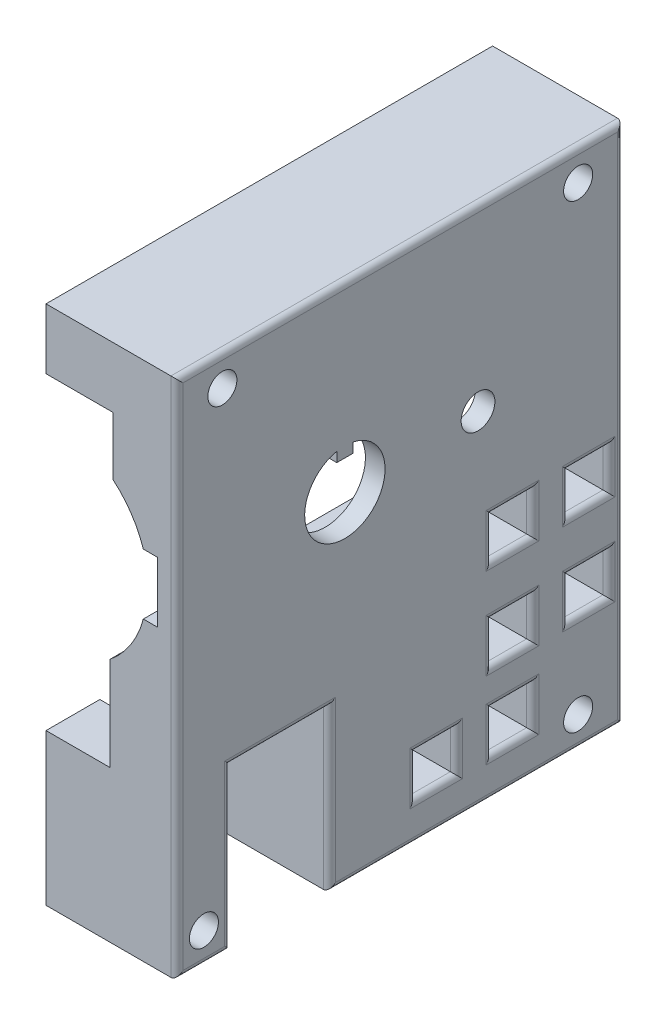
from build123d import *

# Parameters (mm, degrees)
PROFILEEXTRUDE_DEPTH = 73.76
HOSEWINDOW_W         = 16.29
HOSEWINDOW_H         = 26.5
HOSEWINDOWCUT_DEPTH  = 22.63
CAGESCREWS_R         = 2.4
CAGESCREWSCUT_DEPTH  = 22.63
AXLEHOLECUT_DEPTH    = 22.63
SETSCREWS_R          = 2.426338021
SETSCREWS_R_2        = 2.788762315
SETSCREWSCUT_DEPTH   = 22.63
SKETCH1_W            = 6.7
SKETCH1_H            = 6.7
CUT_EXTRUDE1_DEPTH   = 22.63
FILLET1_R            = 1


with BuildPart() as part:
    # Profile → ProfileExtrude (new body)
    with BuildSketch(Plane.XY):
        with BuildLine():
            Line((-6.44073477, -58.62791746), (-6.44073477, -33.62791746))
            Line((-6.44073477, -33.62791746), (4.13926523, -33.62791746))
            Line((4.13926523, -33.62791746), (4.13926523, -18.13791746))
            ThreePointArc((4.13926523, -18.13791746), (7.563334043, -14.326029686), (9.63126523, -9.63791746))
            Line((9.63126523, -9.63791746), (11.94926523, -9.63791746))
            Line((11.94926523, -9.63791746), (11.94926523, 0.36208254))
            Line((11.94926523, 0.36208254), (9.62926523, 0.36208254))
            ThreePointArc((9.62926523, 0.36208254), (7.643946533, 4.440626184), (4.60926523, 7.81208254))
            Line((4.60926523, 7.81208254), (4.60926523, 17.41208254))
            Line((4.60926523, 17.41208254), (-6.44073477, 17.41208254))
            Line((-6.44073477, 17.41208254), (-6.44073477, 27.41208254))
            Line((-6.44073477, 27.41208254), (15.18926523, 27.41208254))
            Line((15.18926523, 27.41208254), (15.18926523, -58.62791746))
            Line((15.18926523, -58.62791746), (-6.44073477, -58.62791746))
        make_face()
    extrude(amount=PROFILEEXTRUDE_DEPTH)

    # HoseWindow → HoseWindowCut (cut, through all)
    with BuildSketch(Plane(origin=(15.18926523, 0, 0), x_dir=(0, 0, -1), z_dir=(1, 0, 0))):
        with Locations((-56.725, -45.37791746)):
            Rectangle(HOSEWINDOW_W, HOSEWINDOW_H)
    extrude(amount=-HOSEWINDOWCUT_DEPTH, mode=Mode.SUBTRACT)

    # CageScrews → CageScrewsCut (cut, through all)
    with BuildSketch(Plane(origin=(15.18926523, 0, 0), x_dir=(0, 0, -1), z_dir=(1, 0, 0))):
        with Locations((-66.26, 22.41208254)):
            Circle(CAGESCREWS_R)
        with Locations((-7.5, 22.41208254)):
            Circle(CAGESCREWS_R)
        with Locations((-7.5, -53.62791746)):
            Circle(CAGESCREWS_R)
        with Locations((-69.31, -53.62791746)):
            Circle(CAGESCREWS_R)
    extrude(amount=-CAGESCREWSCUT_DEPTH, mode=Mode.SUBTRACT)

    # AxleHole → AxleHoleCut (cut, through all)
    with BuildSketch(Plane(origin=(15.18926523, 0, 0), x_dir=(0, 0, -1), z_dir=(1, 0, 0))):
        with BuildLine():
            Line((-44.699, 2.307293484), (-47.361, 2.307293484))
            Line((-47.361, 2.307293484), (-47.361, 3.926293484))
            ThreePointArc((-47.361, 3.926293484), (-46.03, -9.21691746), (-44.699, 3.926293484))
            Line((-44.699, 3.926293484), (-44.699, 2.307293484))
        make_face()
    extrude(amount=-AXLEHOLECUT_DEPTH, mode=Mode.SUBTRACT)

    # SetScrews → SetScrewsCut (cut, through all)
    with BuildSketch(Plane(origin=(15.18926523, 0, 0), x_dir=(0, 0, -1), z_dir=(1, 0, 0))):
        with Locations((-85.624962528, 3.100017238)):
            Circle(SETSCREWS_R)
        with Locations((-24.037149362, -2.017095907)):
            Circle(SETSCREWS_R_2)
    extrude(amount=-SETSCREWSCUT_DEPTH, mode=Mode.SUBTRACT)

    # Sketch1 → Cut-Extrude1 (cut, through all)
    with BuildSketch(Plane(origin=(15.18926523, 0, 0), x_dir=(0, 0, -1), z_dir=(1, 0, 0))):
        with Locations((-18.35, -48.92791746)):
            Rectangle(SKETCH1_W, SKETCH1_H)
        with Locations((-30.95, -48.92791746)):
            Rectangle(SKETCH1_W, SKETCH1_H)
        with Locations((-5.75, -36.22791746)):
            Rectangle(SKETCH1_W, SKETCH1_H)
        with Locations((-18.35, -36.22791746)):
            Rectangle(SKETCH1_W, SKETCH1_H)
        with Locations((-5.75, -21.22791746)):
            Rectangle(SKETCH1_W, SKETCH1_H)
        with Locations((-18.35, -21.22791746)):
            Rectangle(SKETCH1_W, SKETCH1_H)
    extrude(amount=-CUT_EXTRUDE1_DEPTH, mode=Mode.SUBTRACT)

    # Fillet1
    fillet1_edges = [part.edges().sort_by_distance(p)[0] for p in [
        (15.18926523, -45.57791746, 18.35),
        (15.18926523, -48.92791746, 21.7),
        (15.18926523, -52.27791746, 18.35),
        (15.18926523, -48.92791746, 15),
        (15.18926523, -48.92791746, 34.3),
        (15.18926523, -52.27791746, 30.95),
        (15.18926523, -48.92791746, 27.6),
        (15.18926523, -45.57791746, 30.95),
        (15.18926523, -36.22791746, 9.1),
        (15.18926523, -39.57791746, 5.75),
        (15.18926523, -36.22791746, 2.4),
        (15.18926523, -32.87791746, 5.75),
        (15.18926523, -36.22791746, 21.7),
        (15.18926523, -39.57791746, 18.35),
        (15.18926523, -36.22791746, 15),
        (15.18926523, -32.87791746, 18.35),
        (15.18926523, -15.60791746, 0),
        (15.18926523, -21.22791746, 9.1),
        (15.18926523, -24.57791746, 5.75),
        (15.18926523, -21.22791746, 2.4),
        (15.18926523, -17.87791746, 5.75),
        (15.18926523, -21.22791746, 21.7),
        (15.18926523, -24.57791746, 18.35),
        (15.18926523, -21.22791746, 15),
        (15.18926523, -17.87791746, 18.35),
        (15.18926523, -58.62791746, 69.315),
        (15.18926523, 27.41208254, 36.88),
        (15.18926523, -58.62791746, 24.29),
        (15.18926523, -15.60791746, 73.76),
        (15.18926523, -45.37791746, 64.87),
        (15.18926523, -45.37791746, 48.58),
        (15.18926523, -32.12791746, 56.725),
    ]]
    fillet(fillet1_edges, radius=FILLET1_R)


solid = part.part
